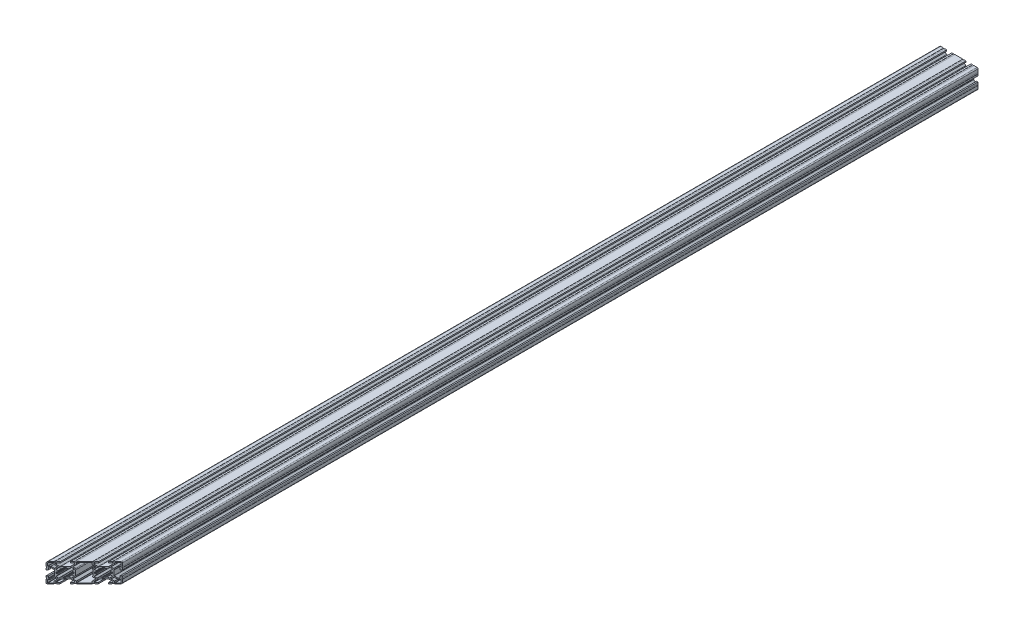
from build123d import *

# Parameters (mm, degrees)
RETANGULAR_PF30_02_PERFIL_3060_B_SICO_DEPTH = 1400
CORTAR_EXTRUIR1_DEPTH                       = 701.803110475
CORTAR_EXTRUIR1_DEPTH_BACK                  = 701.803110475


with BuildPart() as part:
    # Sketch1 → Retangular PF30-02 - PERFIL 3060 BÁSICO(1) (new body)
    with BuildSketch(Plane(origin=(0, 0, 700), x_dir=(0, -1, 0), z_dir=(0, 0, -1))):
        with BuildLine():
            Line((-4.049998685, 29.999996087), (-4.049998685, 27.999995534))
            Line((-4.049998685, 27.999995534), (-7.199996435, 27.999995648))
            ThreePointArc((-7.199996435, 27.999995648), (-7.412128477, 27.912127686), (-7.499996446, 27.699995648))
            Line((-7.499996446, 27.699995648), (-7.499996446, 26.937612154))
            ThreePointArc((-7.499996446, 26.937612154), (-7.477160306, 26.822807125), (-7.412128481, 26.72548012))
            Line((-7.412128481, 26.72548012), (-4.22098228, 23.53433392))
            ThreePointArc((-4.22098228, 23.53433392), (-3.961443601, 23.360915719), (-3.655296856, 23.300019345))
            Line((-3.655296856, 23.300019345), (3.655296879, 23.300019345))
            ThreePointArc((3.655296879, 23.300019345), (3.961443625, 23.360915719), (4.220982304, 23.53433392))
            Line((4.220982304, 23.53433392), (7.412128505, 26.72548012))
            ThreePointArc((7.412128505, 26.72548012), (7.47716033, 26.822807125), (7.49999647, 26.937612154))
            Line((7.49999647, 26.937612154), (7.49999647, 27.699995534))
            ThreePointArc((7.49999647, 27.699995534), (7.412128505, 27.912127568), (7.19999647, 27.999995534))
            Line((7.19999647, 27.999995534), (4.05, 27.999995534))
            Line((4.05, 27.999995534), (4.05, 29.999996185))
            Line((4.05, 29.999996185), (6.599996803, 29.999996185))
            Line((6.599996803, 29.999996185), (6.599996803, 29.699996185))
            Line((6.599996803, 29.699996185), (8.799996803, 29.699996185))
            Line((8.799996803, 29.699996185), (8.799996803, 29.999996087))
            Line((8.799996803, 29.999996087), (13.499995923, 29.999996087))
            ThreePointArc((13.499995923, 29.999996087), (14.560656066, 29.560656231), (14.999995923, 28.499996087))
            Line((14.999995923, 28.499996087), (14.999995923, 23.799996967))
            Line((14.999995923, 23.799996967), (14.699995923, 23.799996967))
            Line((14.699995923, 23.799996967), (14.699995923, 21.599996967))
            Line((14.699995923, 21.599996967), (14.999995923, 21.599996967))
            Line((14.999995923, 21.599996967), (14.999995923, 19.04999885))
            Line((14.999995923, 19.04999885), (12.999995369, 19.04999885))
            Line((12.999995369, 19.04999885), (12.999995483, 22.1999966))
            ThreePointArc((12.999995483, 22.1999966), (12.912127522, 22.412128642), (12.699995483, 22.499996611))
            Line((12.699995483, 22.499996611), (11.93761199, 22.499996611))
            ThreePointArc((11.93761199, 22.499996611), (11.82280696, 22.477160471), (11.725479955, 22.412128645))
            Line((11.725479955, 22.412128645), (8.534333755, 19.220982445))
            ThreePointArc((8.534333755, 19.220982445), (8.360915554, 18.961443766), (8.30001918, 18.65529702))
            Line((8.30001918, 18.65529702), (8.30001918, 11.344703285))
            ThreePointArc((8.30001918, 11.344703285), (8.360915554, 11.038556539), (8.534333755, 10.77901786))
            Line((8.534333755, 10.77901786), (11.725479955, 7.58787166))
            ThreePointArc((11.725479955, 7.58787166), (11.82280696, 7.522839835), (11.93761199, 7.500003694))
            Line((11.93761199, 7.500003694), (12.699995369, 7.500003694))
            ThreePointArc((12.699995369, 7.500003694), (12.912127403, 7.58787166), (12.999995369, 7.800003694))
            Line((12.999995369, 7.800003694), (12.999995369, 10.950000165))
            Line((12.999995369, 10.950000165), (14.99999602, 10.950000165))
            Line((14.99999602, 10.950000165), (14.99999602, 8.400003362))
            Line((14.99999602, 8.400003362), (14.69999602, 8.400003362))
            Line((14.69999602, 8.400003362), (14.69999602, 6.200003362))
            Line((14.69999602, 6.200003362), (14.99999602, 6.200003362))
            Line((14.99999602, 6.200003362), (14.99999602, -6.200003033))
            Line((14.99999602, -6.200003033), (14.69999602, -6.200003033))
            Line((14.69999602, -6.200003033), (14.69999602, -8.400003033))
            Line((14.69999602, -8.400003033), (14.99999602, -8.400003033))
            Line((14.99999602, -8.400003033), (14.99999602, -10.949999835))
            Line((14.99999602, -10.949999835), (12.999995369, -10.949999835))
            Line((12.999995369, -10.949999835), (12.999995369, -7.800003365))
            ThreePointArc((12.999995369, -7.800003365), (12.912127403, -7.587871331), (12.699995369, -7.500003365))
            Line((12.699995369, -7.500003365), (11.93761199, -7.500003365))
            ThreePointArc((11.93761199, -7.500003365), (11.82280696, -7.522839505), (11.725479955, -7.587871331))
            Line((11.725479955, -7.587871331), (8.534333755, -10.779017531))
            ThreePointArc((8.534333755, -10.779017531), (8.360915554, -11.03855621), (8.30001918, -11.344702956))
            Line((8.30001918, -11.344702956), (8.30001918, -18.655296691))
            ThreePointArc((8.30001918, -18.655296691), (8.360915554, -18.961443437), (8.534333755, -19.220982116))
            Line((8.534333755, -19.220982116), (11.725479955, -22.412128316))
            ThreePointArc((11.725479955, -22.412128316), (11.82280696, -22.477160141), (11.93761199, -22.499996282))
            Line((11.93761199, -22.499996282), (12.699995483, -22.499996282))
            ThreePointArc((12.699995483, -22.499996282), (12.912127522, -22.412128312), (12.999995483, -22.199996271))
            Line((12.999995483, -22.199996271), (12.999995369, -19.04999852))
            Line((12.999995369, -19.04999852), (14.999995923, -19.04999852))
            Line((14.999995923, -19.04999852), (14.999995923, -21.599996638))
            Line((14.999995923, -21.599996638), (14.699995923, -21.599996638))
            Line((14.699995923, -21.599996638), (14.699995923, -23.799996638))
            Line((14.699995923, -23.799996638), (14.999995923, -23.799996638))
            Line((14.999995923, -23.799996638), (14.999995923, -28.499995758))
            ThreePointArc((14.999995923, -28.499995758), (14.560656066, -29.560655901), (13.499995923, -29.999995758))
            Line((13.499995923, -29.999995758), (8.799996803, -29.999995758))
            Line((8.799996803, -29.999995758), (8.799996803, -29.699995855))
            Line((8.799996803, -29.699995855), (6.599996803, -29.699995855))
            Line((6.599996803, -29.699995855), (6.599996803, -29.999995855))
            Line((6.599996803, -29.999995855), (4.05, -29.999995855))
            Line((4.05, -29.999995855), (4.05, -27.999995204))
            Line((4.05, -27.999995204), (7.19999647, -27.999995204))
            ThreePointArc((7.19999647, -27.999995204), (7.412128505, -27.912127239), (7.49999647, -27.699995204))
            Line((7.49999647, -27.699995204), (7.49999647, -26.937611825))
            ThreePointArc((7.49999647, -26.937611825), (7.47716033, -26.822806795), (7.412128505, -26.72547979))
            Line((7.412128505, -26.72547979), (4.220982304, -23.53433359))
            ThreePointArc((4.220982304, -23.53433359), (3.961443625, -23.360915389), (3.655296879, -23.300019015))
            Line((3.655296879, -23.300019015), (-3.655296856, -23.300019015))
            ThreePointArc((-3.655296856, -23.300019015), (-3.961443601, -23.360915389), (-4.22098228, -23.53433359))
            Line((-4.22098228, -23.53433359), (-7.412128481, -26.72547979))
            ThreePointArc((-7.412128481, -26.72547979), (-7.477160306, -26.822806795), (-7.499996446, -26.937611825))
            Line((-7.499996446, -26.937611825), (-7.499996446, -27.699995319))
            ThreePointArc((-7.499996446, -27.699995319), (-7.412128477, -27.912127357), (-7.199996435, -27.999995319))
            Line((-7.199996435, -27.999995319), (-4.049998685, -27.999995204))
            Line((-4.049998685, -27.999995204), (-4.049998685, -29.999995758))
            Line((-4.049998685, -29.999995758), (-6.599996803, -29.999995758))
            Line((-6.599996803, -29.999995758), (-6.599996803, -29.699995758))
            Line((-6.599996803, -29.699995758), (-8.799996803, -29.699995758))
            Line((-8.799996803, -29.699995758), (-8.799996803, -29.999995758))
            Line((-8.799996803, -29.999995758), (-13.499995923, -29.999995758))
            ThreePointArc((-13.499995923, -29.999995758), (-14.560656066, -29.560655901), (-14.999995923, -28.499995758))
            Line((-14.999995923, -28.499995758), (-14.999995923, -23.799996638))
            Line((-14.999995923, -23.799996638), (-14.699995923, -23.799996638))
            Line((-14.699995923, -23.799996638), (-14.699995923, -21.599996638))
            Line((-14.699995923, -21.599996638), (-14.999995923, -21.599996638))
            Line((-14.999995923, -21.599996638), (-14.999995923, -19.04999852))
            Line((-14.999995923, -19.04999852), (-12.999995369, -19.04999852))
            Line((-12.999995369, -19.04999852), (-12.999995483, -22.199996271))
            ThreePointArc((-12.999995483, -22.199996271), (-12.912127522, -22.412128312), (-12.699995483, -22.499996282))
            Line((-12.699995483, -22.499996282), (-11.93761199, -22.499996282))
            ThreePointArc((-11.93761199, -22.499996282), (-11.82280696, -22.477160141), (-11.725479955, -22.412128316))
            Line((-11.725479955, -22.412128316), (-8.534333755, -19.220982116))
            ThreePointArc((-8.534333755, -19.220982116), (-8.360915554, -18.961443437), (-8.30001918, -18.655296691))
            Line((-8.30001918, -18.655296691), (-8.30001918, -11.344702956))
            ThreePointArc((-8.30001918, -11.344702956), (-8.360915554, -11.03855621), (-8.534333755, -10.779017531))
            Line((-8.534333755, -10.779017531), (-11.725479955, -7.587871331))
            ThreePointArc((-11.725479955, -7.587871331), (-11.82280696, -7.522839505), (-11.93761199, -7.500003365))
            Line((-11.93761199, -7.500003365), (-12.699995369, -7.500003365))
            ThreePointArc((-12.699995369, -7.500003365), (-12.912127403, -7.587871331), (-12.999995369, -7.800003365))
            Line((-12.999995369, -7.800003365), (-12.999995369, -10.949999835))
            Line((-12.999995369, -10.949999835), (-14.99999602, -10.949999835))
            Line((-14.99999602, -10.949999835), (-14.99999602, -8.400003033))
            Line((-14.99999602, -8.400003033), (-14.69999602, -8.400003033))
            Line((-14.69999602, -8.400003033), (-14.69999602, -6.200003033))
            Line((-14.69999602, -6.200003033), (-14.99999602, -6.200003033))
            Line((-14.99999602, -6.200003033), (-14.99999602, 6.200003362))
            Line((-14.99999602, 6.200003362), (-14.69999602, 6.200003362))
            Line((-14.69999602, 6.200003362), (-14.69999602, 8.400003362))
            Line((-14.69999602, 8.400003362), (-14.99999602, 8.400003362))
            Line((-14.99999602, 8.400003362), (-14.99999602, 10.950000165))
            Line((-14.99999602, 10.950000165), (-12.999995369, 10.950000165))
            Line((-12.999995369, 10.950000165), (-12.999995369, 7.800003694))
            ThreePointArc((-12.999995369, 7.800003694), (-12.912127403, 7.58787166), (-12.699995369, 7.500003694))
            Line((-12.699995369, 7.500003694), (-11.93761199, 7.500003694))
            ThreePointArc((-11.93761199, 7.500003694), (-11.82280696, 7.522839835), (-11.725479955, 7.58787166))
            Line((-11.725479955, 7.58787166), (-8.534333755, 10.77901786))
            ThreePointArc((-8.534333755, 10.77901786), (-8.360915554, 11.038556539), (-8.30001918, 11.344703285))
            Line((-8.30001918, 11.344703285), (-8.30001918, 18.65529702))
            ThreePointArc((-8.30001918, 18.65529702), (-8.360915554, 18.961443766), (-8.534333755, 19.220982445))
            Line((-8.534333755, 19.220982445), (-11.725479955, 22.412128645))
            ThreePointArc((-11.725479955, 22.412128645), (-11.82280696, 22.477160471), (-11.93761199, 22.499996611))
            Line((-11.93761199, 22.499996611), (-12.699995483, 22.499996611))
            ThreePointArc((-12.699995483, 22.499996611), (-12.912127522, 22.412128642), (-12.999995483, 22.1999966))
            Line((-12.999995483, 22.1999966), (-12.999995369, 19.04999885))
            Line((-12.999995369, 19.04999885), (-14.999995923, 19.04999885))
            Line((-14.999995923, 19.04999885), (-14.999995923, 21.599996967))
            Line((-14.999995923, 21.599996967), (-14.699995923, 21.599996967))
            Line((-14.699995923, 21.599996967), (-14.699995923, 23.799996967))
            Line((-14.699995923, 23.799996967), (-14.999995923, 23.799996967))
            Line((-14.999995923, 23.799996967), (-14.999995923, 28.499996087))
            ThreePointArc((-14.999995923, 28.499996087), (-14.560656066, 29.560656231), (-13.499995923, 29.999996087))
            Line((-13.499995923, 29.999996087), (-8.799996803, 29.999996087))
            Line((-8.799996803, 29.999996087), (-8.799996803, 29.699996087))
            Line((-8.799996803, 29.699996087), (-6.599996803, 29.699996087))
            Line((-6.599996803, 29.699996087), (-6.599996803, 29.999996087))
            Line((-6.599996803, 29.999996087), (-4.049998685, 29.999996087))
        make_face()
        with BuildLine():
            Line((-6.025843274, -23.500716843), (-8.712128837, -26.187002406))
            ThreePointArc((-8.712128837, -26.187002406), (-8.777160662, -26.284329411), (-8.799996803, -26.399134441))
            Line((-8.799996803, -26.399134441), (-8.799996803, -28.399996053))
            ThreePointArc((-8.799996803, -28.399996053), (-8.887864768, -28.612128088), (-9.099996803, -28.699996053))
            Line((-9.099996803, -28.699996053), (-13.399996218, -28.699996053))
            ThreePointArc((-13.399996218, -28.699996053), (-13.612128252, -28.612128088), (-13.699996218, -28.399996053))
            Line((-13.699996218, -28.399996053), (-13.699996218, -24.09999627))
            ThreePointArc((-13.699996218, -24.09999627), (-13.612128251, -23.887864234), (-13.399996213, -23.79999627))
            Line((-13.399996213, -23.79999627), (-11.39913459, -23.79999627))
            ThreePointArc((-11.39913459, -23.79999627), (-11.28432956, -23.777160132), (-11.187002554, -23.712128308))
            Line((-11.187002554, -23.712128308), (-8.50071665, -21.025842489))
            ThreePointArc((-8.50071665, -21.025842489), (-8.288584582, -20.937974527), (-8.076452536, -21.025842541))
            Line((-8.076452536, -21.025842541), (-6.025843225, -23.076452792))
            ThreePointArc((-6.025843225, -23.076452792), (-5.937975293, -23.288584828), (-6.025843274, -23.500716843))
        make_face(mode=Mode.SUBTRACT)
        with BuildLine():
            Line((13.699995411, 5.900003245), (13.699995411, -5.900003245))
            ThreePointArc((13.699995411, -5.900003245), (13.612127462, -6.112135263), (13.399995459, -6.200003245))
            Line((13.399995459, -6.200003245), (11.399134078, -6.200003565))
            ThreePointArc((11.399134078, -6.200003565), (11.284329048, -6.222839703), (11.187002043, -6.287871527))
            Line((11.187002043, -6.287871527), (8.500716138, -8.974157346))
            ThreePointArc((8.500716138, -8.974157346), (8.288584071, -9.062025309), (8.076452024, -8.974157294))
            Line((8.076452024, -8.974157294), (6.025842487, -6.923546817))
            ThreePointArc((6.025842487, -6.923546817), (5.073763999, -6.46499579), (4.043474958, -6.700000009))
            Line((4.043474958, -6.700000009), (-4.043474611, -6.700000009))
            ThreePointArc((-4.043474611, -6.700000009), (-5.073763999, -6.464995655), (-6.025842825, -6.923546826))
            Line((-6.025842825, -6.923546826), (-8.076452363, -8.974157303))
            ThreePointArc((-8.076452363, -8.974157303), (-8.288584409, -9.062025317), (-8.500716477, -8.974157355))
            Line((-8.500716477, -8.974157355), (-11.187002381, -6.287871536))
            ThreePointArc((-11.187002381, -6.287871536), (-11.284329387, -6.222839712), (-11.399134417, -6.200003574))
            Line((-11.399134417, -6.200003574), (-13.399995797, -6.200003254))
            ThreePointArc((-13.399995797, -6.200003254), (-13.6121278, -6.112135271), (-13.699995749, -5.900003254))
            Line((-13.699995749, -5.900003254), (-13.699995749, 5.900003237))
            ThreePointArc((-13.699995749, 5.900003237), (-13.6121278, 6.112135254), (-13.399995797, 6.200003237))
            Line((-13.399995797, 6.200003237), (-11.399134417, 6.200003556))
            ThreePointArc((-11.399134417, 6.200003556), (-11.284329387, 6.222839695), (-11.187002381, 6.287871518))
            Line((-11.187002381, 6.287871518), (-8.500716477, 8.974157338))
            ThreePointArc((-8.500716477, 8.974157338), (-8.288584409, 9.0620253), (-8.076452363, 8.974157286))
            Line((-8.076452363, 8.974157286), (-6.025842825, 6.923546808))
            ThreePointArc((-6.025842825, 6.923546808), (-5.073763999, 6.464995638), (-4.043474611, 6.699999991))
            Line((-4.043474611, 6.699999991), (4.043474958, 6.699999991))
            ThreePointArc((4.043474958, 6.699999991), (5.073764124, 6.464995837), (6.025842695, 6.923546939))
            Line((6.025842695, 6.923546939), (8.076452232, 8.974157416))
            ThreePointArc((8.076452232, 8.974157416), (8.288584278, 9.06202543), (8.500716346, 8.974157468))
            Line((8.500716346, 8.974157468), (11.18700225, 6.287871649))
            ThreePointArc((11.18700225, 6.287871649), (11.284329256, 6.222839825), (11.399134286, 6.200003687))
            Line((11.399134286, 6.200003687), (13.399995667, 6.200003367))
            ThreePointArc((13.399995667, 6.200003367), (13.612127579, 6.112135268), (13.699995411, 5.900003245))
        make_face(mode=Mode.SUBTRACT)
        with BuildLine():
            Line((8.076452536, 21.02584287), (6.025843225, 23.076453121))
            ThreePointArc((6.025843225, 23.076453121), (5.937975293, 23.288585157), (6.025843274, 23.500717173))
            Line((6.025843274, 23.500717173), (8.712128837, 26.187002736))
            ThreePointArc((8.712128837, 26.187002736), (8.777160662, 26.284329741), (8.799996803, 26.39913477))
            Line((8.799996803, 26.39913477), (8.799996803, 28.399996383))
            ThreePointArc((8.799996803, 28.399996383), (8.887864768, 28.612128417), (9.099996803, 28.699996383))
            Line((9.099996803, 28.699996383), (13.399996218, 28.699996383))
            ThreePointArc((13.399996218, 28.699996383), (13.612128252, 28.612128417), (13.699996218, 28.399996383))
            Line((13.699996218, 28.399996383), (13.699996218, 24.0999966))
            ThreePointArc((13.699996218, 24.0999966), (13.612128251, 23.887864564), (13.399996213, 23.7999966))
            Line((13.399996213, 23.7999966), (11.39913459, 23.7999966))
            ThreePointArc((11.39913459, 23.7999966), (11.28432956, 23.777160461), (11.187002554, 23.712128638))
            Line((11.187002554, 23.712128638), (8.50071665, 21.025842818))
            ThreePointArc((8.50071665, 21.025842818), (8.288584582, 20.937974856), (8.076452536, 21.02584287))
        make_face(mode=Mode.SUBTRACT)
        with BuildLine():
            Line((-8.712128837, 26.187002736), (-6.025843274, 23.500717173))
            ThreePointArc((-6.025843274, 23.500717173), (-5.937975293, 23.288585157), (-6.025843225, 23.076453121))
            Line((-6.025843225, 23.076453121), (-8.076452536, 21.02584287))
            ThreePointArc((-8.076452536, 21.02584287), (-8.288584582, 20.937974856), (-8.50071665, 21.025842818))
            Line((-8.50071665, 21.025842818), (-11.187002554, 23.712128638))
            ThreePointArc((-11.187002554, 23.712128638), (-11.28432956, 23.777160461), (-11.39913459, 23.7999966))
            Line((-11.39913459, 23.7999966), (-13.399996213, 23.7999966))
            ThreePointArc((-13.399996213, 23.7999966), (-13.612128251, 23.887864564), (-13.699996218, 24.0999966))
            Line((-13.699996218, 24.0999966), (-13.699996218, 28.399996383))
            ThreePointArc((-13.699996218, 28.399996383), (-13.612128252, 28.612128417), (-13.399996218, 28.699996383))
            Line((-13.399996218, 28.699996383), (-9.099996803, 28.699996383))
            ThreePointArc((-9.099996803, 28.699996383), (-8.887864768, 28.612128417), (-8.799996803, 28.399996383))
            Line((-8.799996803, 28.399996383), (-8.799996803, 26.39913477))
            ThreePointArc((-8.799996803, 26.39913477), (-8.777160662, 26.284329741), (-8.712128837, 26.187002736))
        make_face(mode=Mode.SUBTRACT)
        with BuildLine():
            Line((-3.012269005, 9.512857426), (-4.68233992, 7.842786511))
            ThreePointArc((-4.68233992, 7.842786511), (-4.894471848, 7.754918817), (-5.10660394, 7.842786115))
            Line((-5.10660394, 7.842786115), (-7.157214075, 9.893395311))
            ThreePointArc((-7.157214075, 9.893395311), (-7.245082089, 10.105527359), (-7.157214124, 10.317659428))
            Line((-7.157214124, 10.317659428), (-5.487142739, 11.987730813))
            ThreePointArc((-5.487142739, 11.987730813), (-5.403317864, 12.15077611), (-5.430017698, 12.332152783))
            ThreePointArc((-5.430017698, 12.332152783), (-5.679814912, 12.916204489), (-5.86699644, 13.523228474))
            ThreePointArc((-5.86699644, 13.523228474), (-5.973488289, 13.686610043), (-6.157921876, 13.750000127))
            Line((-6.157921876, 13.750000127), (-6.700000148, 13.750000127))
            ThreePointArc((-6.700000148, 13.750000127), (-6.912132183, 13.837868093), (-7.000000148, 14.050000127))
            Line((-7.000000148, 14.050000127), (-7.000000148, 15.950000127))
            ThreePointArc((-7.000000148, 15.950000127), (-6.912132183, 16.162132162), (-6.700000148, 16.250000127))
            Line((-6.700000148, 16.250000127), (-6.157921876, 16.250000127))
            ThreePointArc((-6.157921876, 16.250000127), (-5.973488289, 16.313390212), (-5.86699644, 16.476771781))
            ThreePointArc((-5.86699644, 16.476771781), (-5.679814961, 17.083795655), (-5.430017819, 17.667847259))
            ThreePointArc((-5.430017819, 17.667847259), (-5.403317985, 17.849223932), (-5.48714286, 18.012269229))
            Line((-5.48714286, 18.012269229), (-7.157213775, 19.682340144))
            ThreePointArc((-7.157213775, 19.682340144), (-7.245081741, 19.894472144), (-7.157213823, 20.106604164))
            Line((-7.157213823, 20.106604164), (-5.106604628, 22.157214299))
            ThreePointArc((-5.106604628, 22.157214299), (-4.894472579, 22.245082314), (-4.682340511, 22.157214348))
            Line((-4.682340511, 22.157214348), (-3.012269126, 20.487142963))
            ThreePointArc((-3.012269126, 20.487142963), (-2.849223829, 20.403318088), (-2.667847156, 20.430017922))
            ThreePointArc((-2.667847156, 20.430017922), (-2.083795553, 20.679815072), (-1.47677168, 20.86699656))
            ThreePointArc((-1.47677168, 20.86699656), (-1.313390111, 20.973488409), (-1.250000026, 21.157921996))
            Line((-1.250000026, 21.157921996), (-1.250000026, 21.700000268))
            ThreePointArc((-1.250000026, 21.700000268), (-1.16213206, 21.912132303), (-0.950000026, 22.000000268))
            Line((-0.950000026, 22.000000268), (0.949999974, 22.000000268))
            ThreePointArc((0.949999974, 22.000000268), (1.162132008, 21.912132303), (1.249999974, 21.700000268))
            Line((1.249999974, 21.700000268), (1.249999974, 21.157921996))
            ThreePointArc((1.249999974, 21.157921996), (1.313390037, 20.973488339), (1.476771654, 20.866996456))
            ThreePointArc((1.476771654, 20.866996456), (2.083795477, 20.679814986), (2.667847035, 20.430017862))
            ThreePointArc((2.667847035, 20.430017862), (2.849223708, 20.403318029), (3.012269005, 20.487142904))
            Line((3.012269005, 20.487142904), (4.68234039, 22.157214289))
            ThreePointArc((4.68234039, 22.157214289), (4.894472459, 22.245082254), (5.106604507, 22.15721424))
            Line((5.106604507, 22.15721424), (7.157213703, 20.106604105))
            ThreePointArc((7.157213703, 20.106604105), (7.24508162, 19.894472084), (7.157213654, 19.682340084))
            Line((7.157213654, 19.682340084), (5.487142739, 18.01226917))
            ThreePointArc((5.487142739, 18.01226917), (5.403317864, 17.849223873), (5.430017698, 17.6678472))
            ThreePointArc((5.430017698, 17.6678472), (5.679814822, 17.083795642), (5.866996291, 16.476771818))
            ThreePointArc((5.866996291, 16.476771818), (5.97348814, 16.31339025), (6.157921727, 16.250000165))
            Line((6.157921727, 16.250000165), (6.7, 16.250000165))
            ThreePointArc((6.7, 16.250000165), (6.912132034, 16.162132199), (7, 15.950000165))
            Line((7, 15.950000165), (7, 14.050000165))
            ThreePointArc((7, 14.050000165), (6.912132034, 13.83786813), (6.7, 13.750000165))
            Line((6.7, 13.750000165), (6.157921727, 13.750000165))
            ThreePointArc((6.157921727, 13.750000165), (5.97348814, 13.68661008), (5.866996291, 13.523228511))
            ThreePointArc((5.866996291, 13.523228511), (5.679814822, 12.916204687), (5.430017698, 12.33215313))
            ThreePointArc((5.430017698, 12.33215313), (5.403317864, 12.150776457), (5.487142739, 11.98773116))
            Line((5.487142739, 11.98773116), (7.157214124, 10.317659775))
            ThreePointArc((7.157214124, 10.317659775), (7.245082263, 10.105527533), (7.157214075, 9.893395311))
            Line((7.157214075, 9.893395311), (5.10660394, 7.842786115))
            ThreePointArc((5.10660394, 7.842786115), (4.894471848, 7.754918817), (4.68233992, 7.842786511))
            Line((4.68233992, 7.842786511), (3.012269005, 9.512857426))
            ThreePointArc((3.012269005, 9.512857426), (2.849223708, 9.596682301), (2.667847035, 9.569982467))
            ThreePointArc((2.667847035, 9.569982467), (2.083795477, 9.320185343), (1.476771653, 9.133003873))
            ThreePointArc((1.476771653, 9.133003873), (1.313390085, 9.026512025), (1.25, 8.842078437))
            Line((1.25, 8.842078437), (1.25, 8.300000165))
            ThreePointArc((1.25, 8.300000165), (1.162132034, 8.08786813), (0.95, 8.000000165))
            Line((0.95, 8.000000165), (-0.95, 8.000000165))
            ThreePointArc((-0.95, 8.000000165), (-1.162132034, 8.08786813), (-1.25, 8.300000165))
            Line((-1.25, 8.300000165), (-1.25, 8.842078437))
            ThreePointArc((-1.25, 8.842078437), (-1.313390085, 9.026512025), (-1.476771653, 9.133003873))
            ThreePointArc((-1.476771653, 9.133003873), (-2.083795477, 9.320185343), (-2.667847035, 9.569982467))
            ThreePointArc((-2.667847035, 9.569982467), (-2.849223708, 9.596682301), (-3.012269005, 9.512857426))
        make_face(mode=Mode.SUBTRACT)
        with BuildLine():
            Line((-1.249999924, -8.84207841), (-1.249999924, -8.300000137))
            ThreePointArc((-1.249999924, -8.300000137), (-1.162131958, -8.087868103), (-0.949999924, -8.000000137))
            Line((-0.949999924, -8.000000137), (0.950000076, -8.000000137))
            ThreePointArc((0.950000076, -8.000000137), (1.16213211, -8.087868103), (1.250000076, -8.300000137))
            Line((1.250000076, -8.300000137), (1.250000076, -8.84207841))
            ThreePointArc((1.250000076, -8.84207841), (1.313390224, -9.026511795), (1.476771653, -9.133003544))
            ThreePointArc((1.476771653, -9.133003544), (2.083795477, -9.320185014), (2.667847035, -9.569982138))
            ThreePointArc((2.667847035, -9.569982138), (2.849223708, -9.596681971), (3.012269005, -9.512857096))
            Line((3.012269005, -9.512857096), (4.68233992, -7.842786181))
            ThreePointArc((4.68233992, -7.842786181), (4.894471848, -7.754918488), (5.10660394, -7.842785786))
            Line((5.10660394, -7.842785786), (7.157214075, -9.893394981))
            ThreePointArc((7.157214075, -9.893394981), (7.245082263, -10.105527203), (7.157214124, -10.317659445))
            Line((7.157214124, -10.317659445), (5.487142739, -11.98773083))
            ThreePointArc((5.487142739, -11.98773083), (5.403317864, -12.150776127), (5.430017698, -12.3321528))
            ThreePointArc((5.430017698, -12.3321528), (5.679814822, -12.916204358), (5.866996291, -13.523228182))
            ThreePointArc((5.866996291, -13.523228182), (5.97348814, -13.68660975), (6.157921727, -13.749999835))
            Line((6.157921727, -13.749999835), (6.7, -13.749999835))
            ThreePointArc((6.7, -13.749999835), (6.912132034, -13.837867801), (7, -14.049999835))
            Line((7, -14.049999835), (7, -15.949999835))
            ThreePointArc((7, -15.949999835), (6.912132034, -16.16213187), (6.7, -16.249999835))
            Line((6.7, -16.249999835), (6.157921727, -16.249999835))
            ThreePointArc((6.157921727, -16.249999835), (5.97348814, -16.31338992), (5.866996291, -16.476771489))
            ThreePointArc((5.866996291, -16.476771489), (5.679814822, -17.083795313), (5.430017698, -17.66784687))
            ThreePointArc((5.430017698, -17.66784687), (5.403317864, -17.849223543), (5.487142739, -18.01226884))
            Line((5.487142739, -18.01226884), (7.157213654, -19.682339755))
            ThreePointArc((7.157213654, -19.682339755), (7.24508162, -19.894471755), (7.157213703, -20.106603775))
            Line((7.157213703, -20.106603775), (5.106604507, -22.157213911))
            ThreePointArc((5.106604507, -22.157213911), (4.894472459, -22.245081925), (4.68234039, -22.157213959))
            Line((4.68234039, -22.157213959), (3.012269005, -20.487142574))
            ThreePointArc((3.012269005, -20.487142574), (2.849223708, -20.403317699), (2.667847035, -20.430017533))
            ThreePointArc((2.667847035, -20.430017533), (2.083795477, -20.679814657), (1.476771654, -20.866996127))
            ThreePointArc((1.476771654, -20.866996127), (1.313390085, -20.973487976), (1.25, -21.157921563))
            Line((1.25, -21.157921563), (1.25, -21.699999835))
            ThreePointArc((1.25, -21.699999835), (1.162132034, -21.91213187), (0.95, -21.999999835))
            Line((0.95, -21.999999835), (-0.95, -21.999999835))
            ThreePointArc((-0.95, -21.999999835), (-1.162132034, -21.91213187), (-1.25, -21.699999835))
            Line((-1.25, -21.699999835), (-1.25, -21.157921563))
            ThreePointArc((-1.25, -21.157921563), (-1.313390085, -20.973487976), (-1.476771654, -20.866996127))
            ThreePointArc((-1.476771654, -20.866996127), (-2.083795477, -20.679814657), (-2.667847035, -20.430017533))
            ThreePointArc((-2.667847035, -20.430017533), (-2.849223708, -20.403317699), (-3.012269005, -20.487142574))
            Line((-3.012269005, -20.487142574), (-4.68234039, -22.157213959))
            ThreePointArc((-4.68234039, -22.157213959), (-4.894472459, -22.245081925), (-5.106604507, -22.157213911))
            Line((-5.106604507, -22.157213911), (-7.157213703, -20.106603775))
            ThreePointArc((-7.157213703, -20.106603775), (-7.24508162, -19.894471755), (-7.157213654, -19.682339755))
            Line((-7.157213654, -19.682339755), (-5.487142739, -18.01226884))
            ThreePointArc((-5.487142739, -18.01226884), (-5.403317864, -17.849223543), (-5.430017698, -17.66784687))
            ThreePointArc((-5.430017698, -17.66784687), (-5.679814822, -17.083795313), (-5.866996291, -16.476771489))
            ThreePointArc((-5.866996291, -16.476771489), (-5.97348814, -16.31338992), (-6.157921727, -16.249999835))
            Line((-6.157921727, -16.249999835), (-6.7, -16.249999835))
            ThreePointArc((-6.7, -16.249999835), (-6.912132034, -16.16213187), (-7, -15.949999835))
            Line((-7, -15.949999835), (-7, -14.049999835))
            ThreePointArc((-7, -14.049999835), (-6.912132034, -13.837867801), (-6.7, -13.749999835))
            Line((-6.7, -13.749999835), (-6.157921727, -13.749999835))
            ThreePointArc((-6.157921727, -13.749999835), (-5.97348814, -13.68660975), (-5.866996291, -13.523228182))
            ThreePointArc((-5.866996291, -13.523228182), (-5.679814822, -12.916204358), (-5.430017698, -12.3321528))
            ThreePointArc((-5.430017698, -12.3321528), (-5.403317864, -12.150776127), (-5.487142739, -11.98773083))
            Line((-5.487142739, -11.98773083), (-7.157214124, -10.317659445))
            ThreePointArc((-7.157214124, -10.317659445), (-7.245082089, -10.105527377), (-7.157214075, -9.893395328))
            Line((-7.157214075, -9.893395328), (-5.10660394, -7.842786133))
            ThreePointArc((-5.10660394, -7.842786133), (-4.894471848, -7.754918835), (-4.68233992, -7.842786528))
            Line((-4.68233992, -7.842786528), (-3.012269005, -9.512857443))
            ThreePointArc((-3.012269005, -9.512857443), (-2.849223708, -9.596682318), (-2.667847035, -9.569982485))
            ThreePointArc((-2.667847035, -9.569982485), (-2.083795442, -9.320185332), (-1.476771577, -9.133003846))
            ThreePointArc((-1.476771577, -9.133003846), (-1.313390009, -9.026511997), (-1.249999924, -8.84207841))
        make_face(mode=Mode.SUBTRACT)
        with BuildLine():
            Line((6.025843225, -23.076452792), (8.076452536, -21.025842541))
            ThreePointArc((8.076452536, -21.025842541), (8.288584582, -20.937974527), (8.50071665, -21.025842489))
            Line((8.50071665, -21.025842489), (11.187002554, -23.712128308))
            ThreePointArc((11.187002554, -23.712128308), (11.28432956, -23.777160132), (11.39913459, -23.79999627))
            Line((11.39913459, -23.79999627), (13.399996213, -23.79999627))
            ThreePointArc((13.399996213, -23.79999627), (13.612128251, -23.887864234), (13.699996218, -24.09999627))
            Line((13.699996218, -24.09999627), (13.699996218, -28.399996053))
            ThreePointArc((13.699996218, -28.399996053), (13.612128252, -28.612128088), (13.399996218, -28.699996053))
            Line((13.399996218, -28.699996053), (9.099996803, -28.699996053))
            ThreePointArc((9.099996803, -28.699996053), (8.887864768, -28.612128088), (8.799996803, -28.399996053))
            Line((8.799996803, -28.399996053), (8.799996803, -26.399134441))
            ThreePointArc((8.799996803, -26.399134441), (8.777160662, -26.284329411), (8.712128837, -26.187002406))
            Line((8.712128837, -26.187002406), (6.025843274, -23.500716843))
            ThreePointArc((6.025843274, -23.500716843), (5.937975293, -23.288584828), (6.025843225, -23.076452792))
        make_face(mode=Mode.SUBTRACT)
    extrude(amount=RETANGULAR_PF30_02_PERFIL_3060_B_SICO_DEPTH)

    # Croquis1 → Cortar-Extruir1 (cut, two sides)
    with BuildSketch(Plane(origin=(0, 0, 0), x_dir=(1, 0, 0), z_dir=(0, 1, 0))) as cortar_extruir1_sk:
        Polygon((-29.999996087, -700), (29.999995758, -640.000008155), (29.999995758, -700), align=None)
    extrude(amount=CORTAR_EXTRUIR1_DEPTH, mode=Mode.SUBTRACT)
    extrude(cortar_extruir1_sk.sketch, amount=-CORTAR_EXTRUIR1_DEPTH_BACK, mode=Mode.SUBTRACT)


solid = part.part
